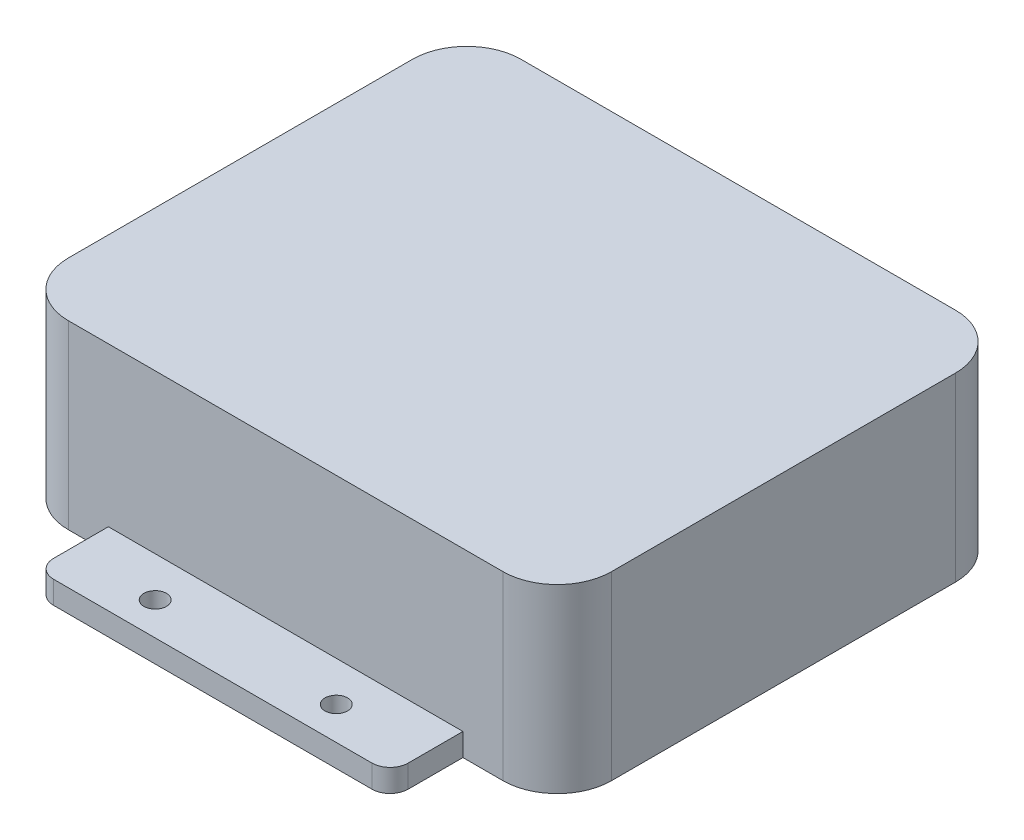
from build123d import *

# Parameters (mm, degrees)
BOSS_EXTRUDE1_DEPTH = 25.4
SKETCH2_R           = 1.5875
BOSS_EXTRUDE2_DEPTH = 3.175


with BuildPart() as part:
    # Sketch1 → Boss-Extrude1 (new body)
    with BuildSketch(Plane(origin=(0, 0, 0), x_dir=(1, 0, 0), z_dir=(0, 1, 0))):
        with BuildLine():
            Line((-30.48, -31.75), (30.48, -31.75))
            ThreePointArc((30.48, -31.75), (35.868153673, -29.518153673), (38.1, -24.13))
            Line((38.1, -24.13), (38.1, 24.13))
            ThreePointArc((38.1, 24.13), (35.868153673, 29.518153673), (30.48, 31.75))
            Line((30.48, 31.75), (-30.48, 31.75))
            ThreePointArc((-30.48, 31.75), (-35.868153673, 29.518153673), (-38.1, 24.13))
            Line((-38.1, 24.13), (-38.1, -24.13))
            ThreePointArc((-38.1, -24.13), (-35.868153673, -29.518153673), (-30.48, -31.75))
        make_face()
    extrude(amount=BOSS_EXTRUDE1_DEPTH)

    # Sketch2 → Boss-Extrude2 (add)
    with BuildSketch(Plane(origin=(0, 0, 0), x_dir=(1, 0, 0), z_dir=(0, 1, 0))):
        with BuildLine():
            Line((-24.869490834, -31.75), (24.869490834, -31.75))
            Line((24.869490834, -31.75), (24.869490834, -39.431167642))
            ThreePointArc((24.869490834, -39.431167642), (24.125542058, -41.227218866), (22.329490834, -41.971167642))
            Line((22.329490834, -41.971167642), (-22.329490834, -41.971167642))
            ThreePointArc((-22.329490834, -41.971167642), (-24.125542058, -41.227218866), (-24.869490834, -39.431167642))
            Line((-24.869490834, -39.431167642), (-24.869490834, -31.75))
        make_face()
        with Locations((12.7, -37.35)):
            Circle(SKETCH2_R, mode=Mode.SUBTRACT)
        with Locations((-12.7, -37.35)):
            Circle(SKETCH2_R, mode=Mode.SUBTRACT)
        with BuildLine():
            Line((-24.869490834, 31.75), (-24.869490834, 39.431167642))
            ThreePointArc((-24.869490834, 39.431167642), (-24.125542058, 41.227218866), (-22.329490834, 41.971167642))
            Line((-22.329490834, 41.971167642), (22.329490834, 41.971167642))
            ThreePointArc((22.329490834, 41.971167642), (24.125542058, 41.227218866), (24.869490834, 39.431167642))
            Line((24.869490834, 39.431167642), (24.869490834, 31.75))
            Line((24.869490834, 31.75), (-24.869490834, 31.75))
        make_face()
        with Locations((12.7, 37.35)):
            Circle(SKETCH2_R, mode=Mode.SUBTRACT)
        with Locations((-12.7, 37.35)):
            Circle(SKETCH2_R, mode=Mode.SUBTRACT)
    extrude(amount=BOSS_EXTRUDE2_DEPTH)


solid = part.part
